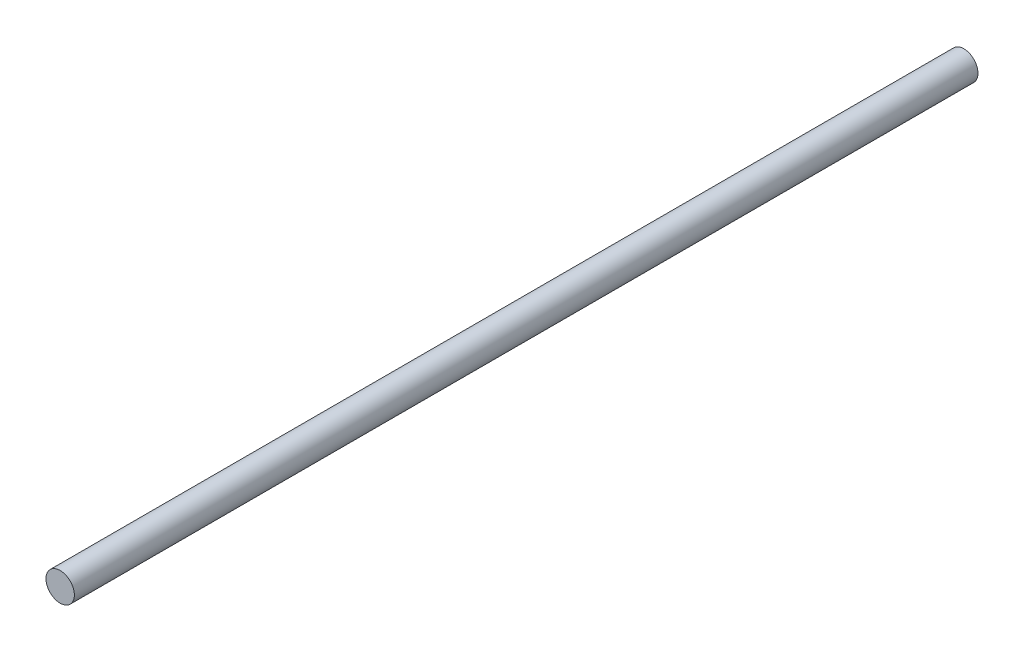
from build123d import *

# Parameters (mm, degrees)
SKETCH1_R           = 3.9878
BOSS_EXTRUDE1_DEPTH = 254


with BuildPart() as part:
    # Sketch1 → Boss-Extrude1 (new body)
    with BuildSketch(Plane.XY):
        Circle(SKETCH1_R)
    extrude(amount=BOSS_EXTRUDE1_DEPTH)


solid = part.part
